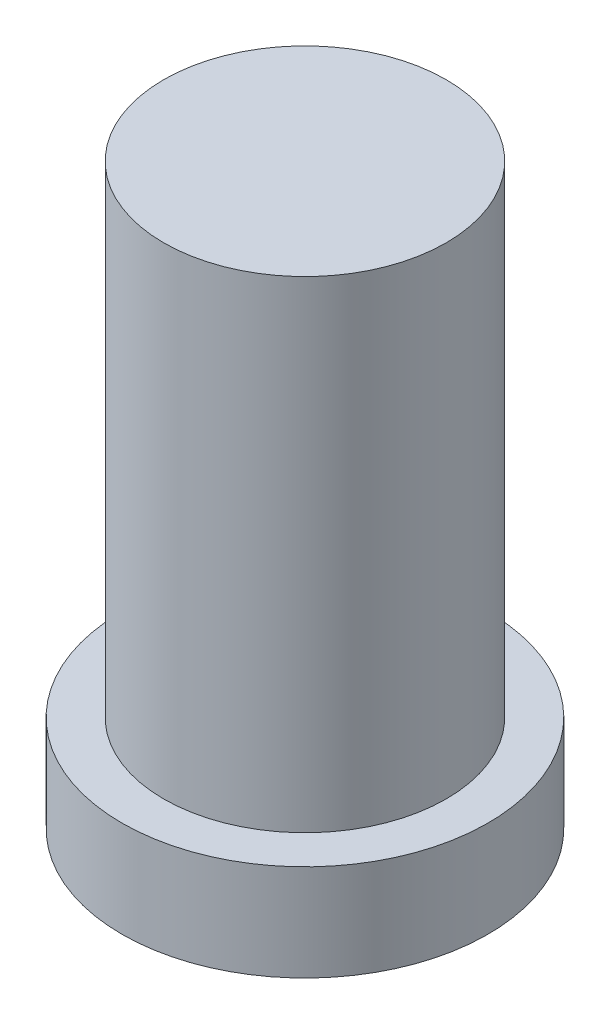
from build123d import *

# Parameters (mm, degrees)
SKETCH1_R           = 28.5
BOSS_EXTRUDE1_DEPTH = 15
SKETCH2_R           = 22
BOSS_EXTRUDE2_DEPTH = 75


with BuildPart() as part:
    # Sketch1 → Boss-Extrude1 (new body)
    with BuildSketch(Plane(origin=(0, 0, 0), x_dir=(1, 0, 0), z_dir=(0, 1, 0))):
        with Locations(Location((0, 0, 0), (0, 0, 270))):  # turned: the seam where the file's is
            Circle(SKETCH1_R)
    extrude(amount=BOSS_EXTRUDE1_DEPTH)

    # Sketch2 → Boss-Extrude2 (add)
    with BuildSketch(Plane(origin=(0, 15, 0), x_dir=(1, 0, 0), z_dir=(0, 1, 0))):
        with Locations(Location((0, 0, 0), (0, 0, 270))):  # turned: the seam where the file's is
            Circle(SKETCH2_R)
    extrude(amount=BOSS_EXTRUDE2_DEPTH)


solid = part.part
